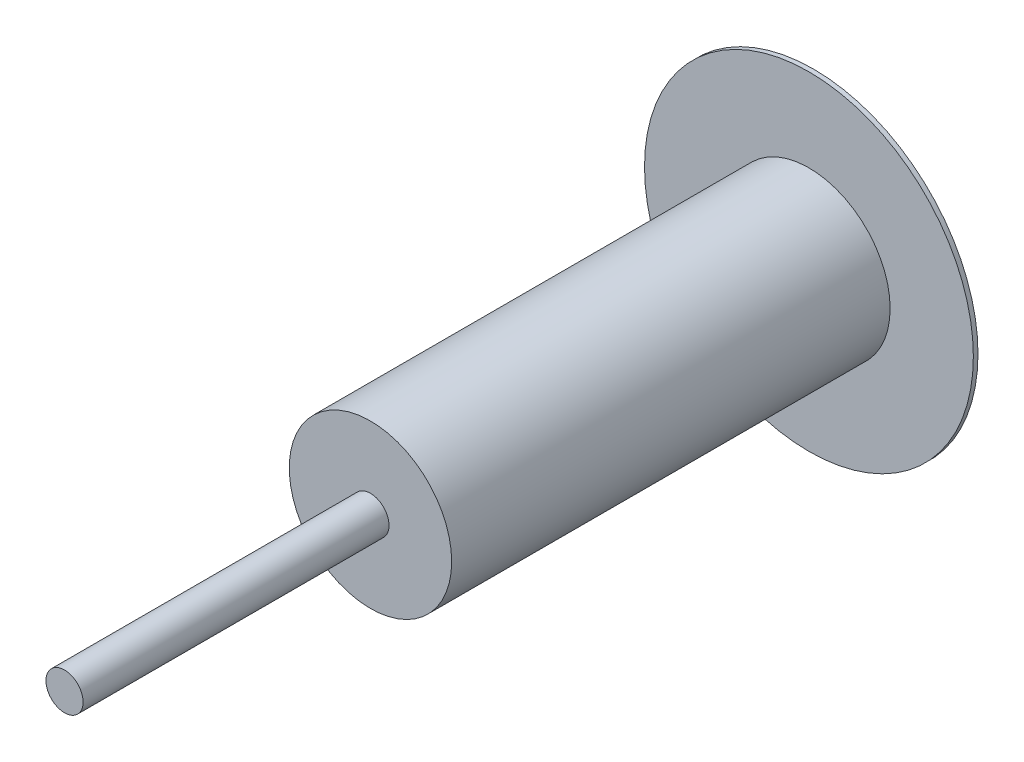
from build123d import *

# Parameters (mm, degrees)
SKETCH1_R                = 50.8
BOSS_EXTRUDE1_DEPTH      = 686.4
BOSS_EXTRUDE1_DEPTH_BACK = 1363.6
SKETCH2_R                = 450
BOSS_EXTRUDE2_DEPTH      = 12.7
SKETCH3_R                = 222.25
BOSS_EXTRUDE3_DEPTH      = 1200


with BuildPart() as part:
    # Sketch1 → Boss-Extrude1 (new body, two sides)
    with BuildSketch(Plane.XY) as boss_extrude1_sk:
        Circle(SKETCH1_R)
    extrude(amount=BOSS_EXTRUDE1_DEPTH)
    extrude(boss_extrude1_sk.sketch, amount=-BOSS_EXTRUDE1_DEPTH_BACK)

    # Sketch2 → Boss-Extrude2 (add)
    with BuildSketch(Plane.XY.offset(-1363.6)):
        Circle(SKETCH2_R)
    extrude(amount=BOSS_EXTRUDE2_DEPTH)

    # Sketch3 → Boss-Extrude3 (add)
    with BuildSketch(Plane.XY.offset(-1350.9)):
        Circle(SKETCH3_R)
    extrude(amount=BOSS_EXTRUDE3_DEPTH)


solid = part.part
